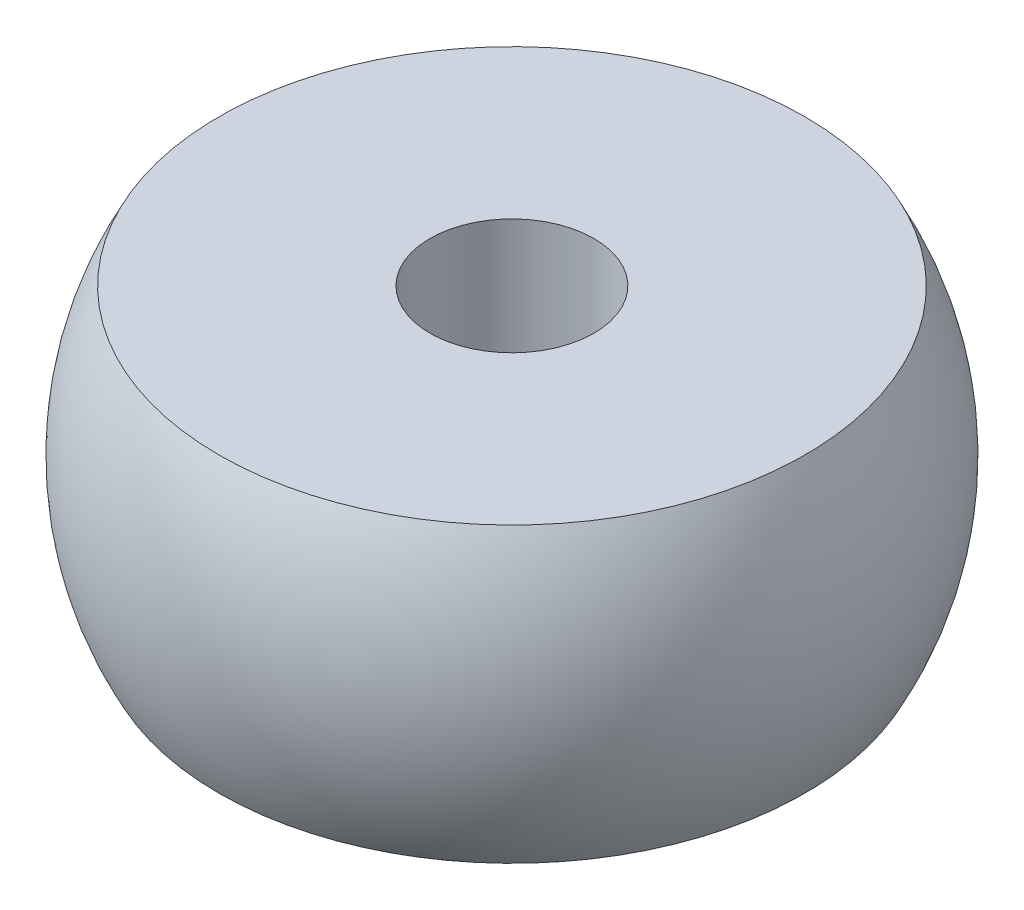
from build123d import *


with BuildPart() as part:
    # Sketch1 → Revolve1 (revolve)
    with BuildSketch(Plane.XY):
        with BuildLine():
            Line((-6.35, 3.175), (-1.778, 3.175))
            Line((-1.778, 3.175), (-1.778, -3.175))
            Line((-1.778, -3.175), (-6.35, -3.175))
            ThreePointArc((-6.35, -3.175), (-7.14375, 0), (-6.35, 3.175))
        make_face()
    revolve(axis=Axis((0, 0, 0), (0, 1, 0)))


solid = part.part
